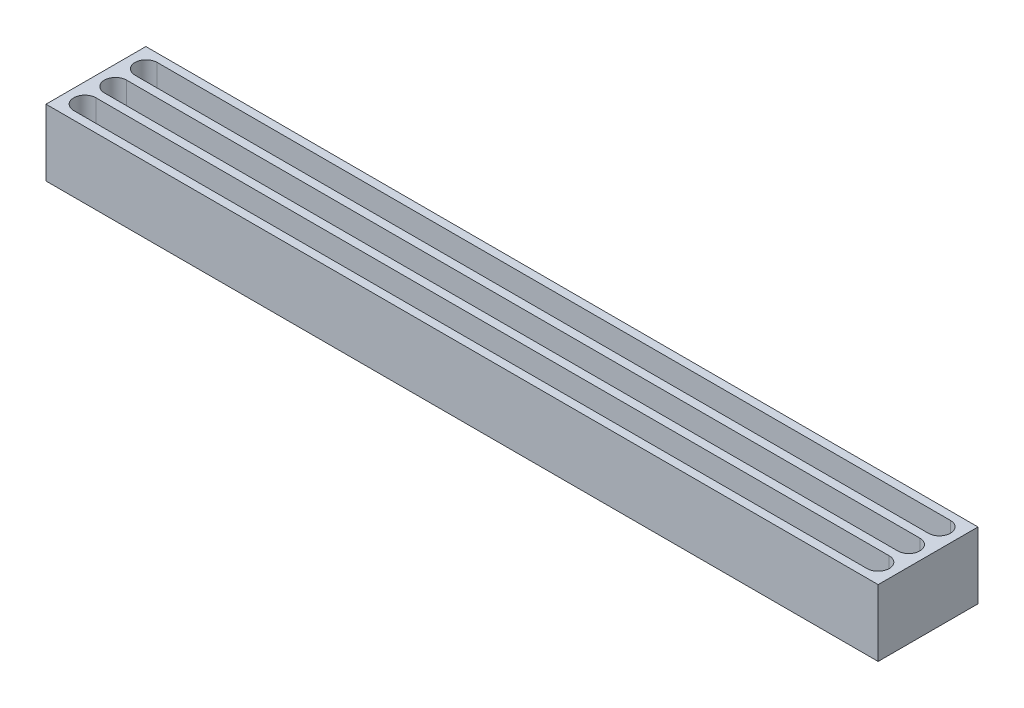
from build123d import *

# Parameters (mm, degrees)
SKETCH1_W           = 635
SKETCH1_H           = 76.2
BOSS_EXTRUDE1_DEPTH = 50.8


with BuildPart() as part:
    # Sketch1 → Boss-Extrude1 (new body)
    with BuildSketch(Plane(origin=(0, 0, 0), x_dir=(1, 0, 0), z_dir=(0, 1, 0))):
        Rectangle(SKETCH1_W, SKETCH1_H)
        with BuildLine():
            Line((302.683333333, -8.382), (-302.683333333, -8.382))
            ThreePointArc((-302.683333333, -8.382), (-311.15, 0.084666667), (-302.683333333, 8.551333333))
            Line((-302.683333333, 8.551333333), (302.683333333, 8.551333333))
            ThreePointArc((302.683333333, 8.551333333), (311.15, 0.084666667), (302.683333333, -8.382))
        make_face(mode=Mode.SUBTRACT)
        with BuildLine():
            Line((302.683333333, -31.75), (-302.683333333, -31.75))
            ThreePointArc((-302.683333333, -31.75), (-311.15, -23.283333333), (-302.683333333, -14.816666667))
            Line((-302.683333333, -14.816666667), (302.683333333, -14.816666667))
            ThreePointArc((302.683333333, -14.816666667), (311.15, -23.283333333), (302.683333333, -31.75))
        make_face(mode=Mode.SUBTRACT)
        with BuildLine():
            Line((302.683333333, 14.986), (-302.683333333, 14.986))
            ThreePointArc((-302.683333333, 14.986), (-311.15, 23.452666667), (-302.683333333, 31.919333333))
            Line((-302.683333333, 31.919333333), (302.683333333, 31.919333333))
            ThreePointArc((302.683333333, 31.919333333), (311.15, 23.452666667), (302.683333333, 14.986))
        make_face(mode=Mode.SUBTRACT)
    extrude(amount=-BOSS_EXTRUDE1_DEPTH)


solid = part.part
